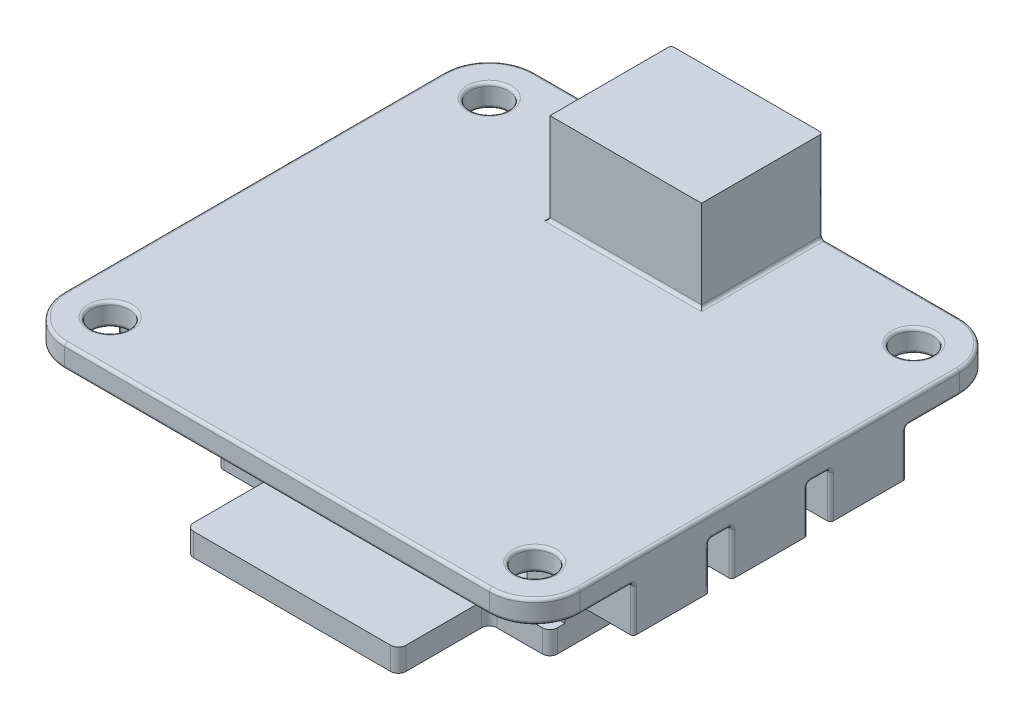
from build123d import *

# Parameters (mm, degrees)
SKETCH_1_W         = 34
SKETCH_1_H         = 31
PCB_DEPTH          = 1.5
SKETCH_2_R         = 1.25
PCB_2_DEPTH        = 1.5
SKETCH_4_W         = 4
SKETCH_4_H         = 5
SKETCH_4_H_2       = 4
EXTRUDE_1_DEPTH    = 3
SKETCH_3_W         = 10
SKETCH_3_H         = 8
EXTRUDE_2364_DEPTH = 6
SKETCH_7_W         = 2.5
SKETCH_7_H         = 16
EXTRUDE_2714_DEPTH = 6
EXTRUDE_C3_DEPTH   = 1.5
USB_C_DEPTH        = 7
FILLET_1_R         = 0.5
SKETCH_10_W        = 2
SKETCH_10_H        = 2
LED_DEPTH          = 1
FILLET_2_R         = 0.2


with BuildPart() as part:
    # 草图1 → PCB (new body)
    with BuildSketch(Plane(origin=(0, 0, 0), x_dir=(1, 0, 0), z_dir=(0, 1, 0))):
        Rectangle(SKETCH_1_W, SKETCH_1_H)
    extrude(amount=PCB_DEPTH)

    # 草图2 → PCB 2 (cut)
    with BuildSketch(Plane(origin=(0, 1.5, 0), x_dir=(1, 0, 0), z_dir=(0, 1, 0))):
        with Locations((14, 12.5)):
            Circle(SKETCH_2_R)
        with Locations((-14, 12.5)):
            Circle(SKETCH_2_R)
        with BuildLine():
            ThreePointArc((-17, 12.5), (-16.121320347, 14.62132034), (-14.000000009, 15.5))
            Line((-14.000000009, 15.5), (-17, 15.5))
            Line((-17, 15.5), (-17, 12.5))
        make_face()
        with BuildLine():
            Line((17, 15.5), (14, 15.5))
            ThreePointArc((14, 15.5), (16.121320344, 14.621320344), (17, 12.5))
            Line((17, 12.5), (17, 15.5))
        make_face()
        with BuildLine():
            ThreePointArc((-14.000000009, -15.5), (-16.121320347, -14.62132034), (-17, -12.5))
            Line((-17, -12.5), (-17, -15.5))
            Line((-17, -15.5), (-14.000000009, -15.5))
        make_face()
        with BuildLine():
            Line((17, -15.5), (17, -12.5))
            ThreePointArc((17, -12.5), (16.121320335, -14.621320352), (13.999999976, -15.5))
            Line((13.999999976, -15.5), (17, -15.5))
        make_face()
        with Locations((14, -12.5)):
            Circle(SKETCH_2_R)
        with Locations((-14, -12.5)):
            Circle(SKETCH_2_R)
    extrude(amount=-PCB_2_DEPTH, mode=Mode.SUBTRACT)

    # 草图4 → 凸台-拉伸1 (add)
    with BuildSketch(Plane(origin=(0, 0, 0), x_dir=(1, 0, 0), z_dir=(0, 1, 0))):
        with Locations((-15, 6.5)):
            Rectangle(SKETCH_4_W, SKETCH_4_H)
        with Locations((-15, 0)):
            Rectangle(SKETCH_4_W, SKETCH_4_H)
        with Locations((-15, -6.5)):
            Rectangle(SKETCH_4_W, SKETCH_4_H)
        with Locations((-7.5, 13.5)):
            Rectangle(SKETCH_4_W, SKETCH_4_H_2)
        with Locations((15, 6.5)):
            Rectangle(SKETCH_4_W, SKETCH_4_H)
        with Locations((-2.5, 13.5)):
            Rectangle(SKETCH_4_W, SKETCH_4_H_2)
        with Locations((2.5, 13.5)):
            Rectangle(SKETCH_4_W, SKETCH_4_H_2)
        with Locations((7.5, 13.5)):
            Rectangle(SKETCH_4_W, SKETCH_4_H_2)
        with Locations((15, 0)):
            Rectangle(SKETCH_4_W, SKETCH_4_H)
        with Locations((15, -6.5)):
            Rectangle(SKETCH_4_W, SKETCH_4_H)
    extrude(amount=-EXTRUDE_1_DEPTH)

    # 草图3 → Extrude 2364 (add)
    with BuildSketch(Plane(origin=(0, 1.5, 0), x_dir=(1, 0, 0), z_dir=(0, 1, 0))):
        with Locations((0, 11.5)):
            Rectangle(SKETCH_3_W, SKETCH_3_H)
    extrude(amount=EXTRUDE_2364_DEPTH)

    # 草图7 → Extrude 2714 (add)
    with BuildSketch(Plane.XZ):
        with Locations((9.75, -0.5)):
            Rectangle(SKETCH_7_W, SKETCH_7_H)
        with Locations((-9.75, -0.5)):
            Rectangle(SKETCH_7_W, SKETCH_7_H)
    extrude(amount=EXTRUDE_2714_DEPTH)

    # 草图8 → 凸台-拉伸-C3核心板 (add)
    with BuildSketch(Plane.XZ.offset(6)):
        Polygon((-11, 8.5), (-7, 8.5), (-7, 14.5), (7, 14.5), (7, 8.5), (11, 8.5), (11, -8.5), (5.5, -8.5), (5.5, -12.5), (-5.5, -12.5), (-5.5, -8.5), (-11, -8.5), align=None)
    extrude(amount=EXTRUDE_C3_DEPTH)

    # 草图9 → 凸台-拉伸-USB-C (add)
    with BuildSketch(Plane(origin=(0, 0, -6.5), x_dir=(-1, 0, 0), z_dir=(0, 0, -1))):
        with BuildLine():
            Line((-3, -7.5), (3, -7.5))
            ThreePointArc((3, -7.5), (4.5, -9), (3, -10.5))
            Line((3, -10.5), (-3, -10.5))
            ThreePointArc((-3, -10.5), (-4.5, -9), (-3, -7.5))
        make_face()
    extrude(amount=USB_C_DEPTH)

    # 圆角1
    fillet_1_edges = [part.edges().sort_by_distance(p)[0] for p in [
        (-11, -6.75, 8.5),
        (-7, -6.75, 14.5),
        (-7, -6.75, 8.5),
        (7, -6.75, 8.5),
        (7, -6.75, 14.5),
        (11, -6.75, 8.5),
        (11, -3.75, -8.5),
        (5.5, -6.75, -8.5),
        (-5.5, -6.75, -8.5),
        (-11, -3.75, -8.5),
        (-5.5, -6.75, -12.5),
        (5.5, -6.75, -12.5),
    ]]
    fillet(fillet_1_edges, radius=FILLET_1_R)

    # 草图10 → 凸台-拉伸-LED (add)
    with BuildSketch(Plane.XZ.offset(7.5)):
        with Locations((-3.8, -3.3)):
            Rectangle(SKETCH_10_W, SKETCH_10_H)
    extrude(amount=LED_DEPTH)

    # 圆角2
    fillet_2_edges = [part.edges().sort_by_distance(p)[0] for p in [
        (17, -1.5, 4),
        (17, -1.5, 2.5),
        (17, -1.5, -2.5),
        (17, -1.5, -4),
        (17, -1.5, -9),
        (9.5, -1.5, -15.5),
        (5.5, -1.5, -15.5),
        (4.5, -1.5, -15.5),
        (0.5, -1.5, -15.5),
        (-0.5, -1.5, -15.5),
        (-4.5, -1.5, -15.5),
        (-5.5, -1.5, -15.5),
        (-9.5, -1.5, -15.5),
        (-17, -1.5, -9),
        (-17, -1.5, -4),
        (-17, -1.5, -2.5),
        (-17, -1.5, 2.5),
        (-17, -1.5, 4),
        (-17, -1.5, 9),
        (17, -1.5, 9),
        (5, 4.5, -15.5),
        (-5, 4.5, -15.5),
        (-10.853553391, 0, -8.353553391),
        (-9.5, 0, -8.5),
        (-8.5, 0, -0.5),
        (-9.75, 0, 7.5),
        (-11, 0, -0.25),
        (-15.25, 0, -12.5),
        (-15.25, 0, 12.5),
        (12.75, 0, 12.5),
        (12.75, 0, -12.5),
        (15, 0, 4),
        (17, 0, 3.25),
        (15, 0, 2.5),
        (13, 0, 0),
        (15, 0, -2.5),
        (17, 0, -3.25),
        (15, 0, -4),
        (13, 0, -6.5),
        (15, 0, -9),
        (17, 0, -10.75),
        (16.121320344, 0, -14.621320344),
        (11.75, 0, -15.5),
        (9.5, 0, -13.5),
        (7.5, 0, -11.5),
        (5.5, 0, -13.5),
        (5, 0, -15.5),
        (4.5, 0, -13.5),
        (2.5, 0, -11.5),
        (0.5, 0, -13.5),
        (0, 0, -15.5),
        (-0.5, 0, -13.5),
        (-2.5, 0, -11.5),
        (-4.5, 0, -13.5),
        (-5, 0, -15.5),
        (-5.5, 0, -13.5),
        (-7.5, 0, -11.5),
        (-9.5, 0, -13.5),
        (-11.750000005, 0, -15.5),
        (-16.121320347, 0, -14.62132034),
        (-17, 0, -10.75),
        (-15, 0, -9),
        (-13, 0, -6.5),
        (-15, 0, -4),
        (-17, 0, -3.25),
        (-15, 0, -2.5),
        (-13, 0, 0),
        (-15, 0, 2.5),
        (-17, 0, 3.25),
        (-15, 0, 4),
        (-13, 0, 6.5),
        (-15, 0, 9),
        (-17, 0, 10.75),
        (-16.121320347, 0, 14.62132034),
        (-1.6e-08, 0, 15.5),
        (16.121320335, 0, 14.621320352),
        (17, 0, 10.75),
        (15, 0, 9),
        (13, 0, 6.5),
        (9.75, 0, 7.5),
        (8.5, 0, -0.5),
        (9.5, 0, -8.5),
        (10.853553391, 0, -8.353553391),
        (11, 0, -0.25),
        (-15.25, 1.5, -12.5),
        (-15.25, 1.5, 12.5),
        (12.75, 1.5, 12.5),
        (12.75, 1.5, -12.5),
        (0, 1.5, -7.5),
        (5, 1.5, -11.5),
        (9.5, 1.5, -15.5),
        (16.121320344, 1.5, -14.621320344),
        (17, 1.5, 0),
        (16.121320335, 1.5, 14.621320352),
        (-1.6e-08, 1.5, 15.5),
        (-16.121320347, 1.5, 14.62132034),
        (-17, 1.5, 0),
        (-16.121320347, 1.5, -14.62132034),
        (-9.500000005, 1.5, -15.5),
        (-5, 1.5, -11.5),
    ]]
    fillet(fillet_2_edges, radius=FILLET_2_R)


solid = part.part
